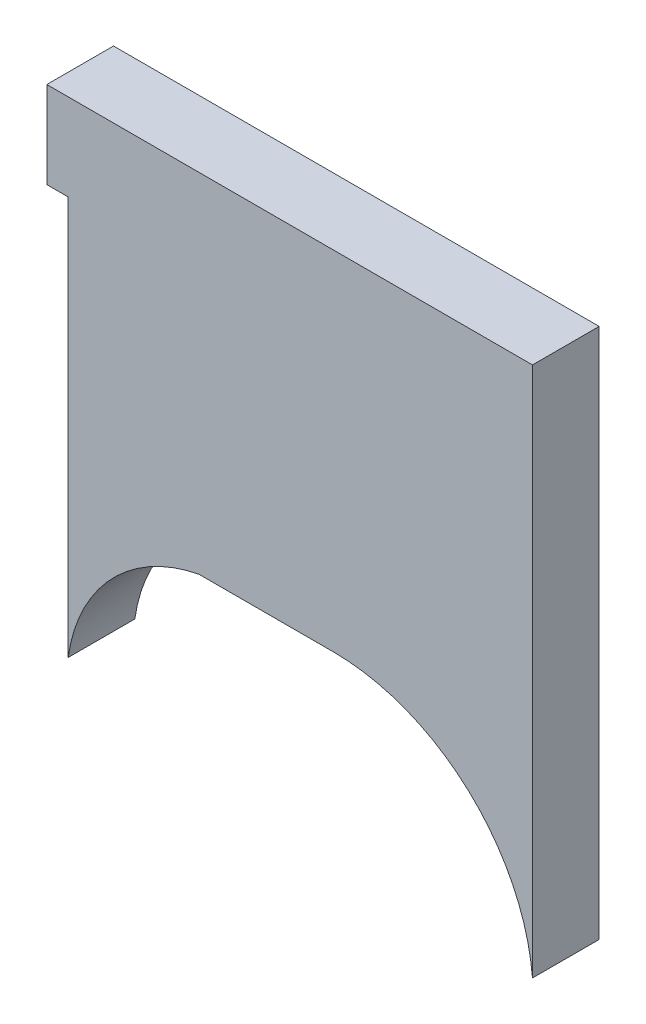
from build123d import *

# Parameters (mm, degrees)
BOSS_EXTRUDE1_DEPTH = 3.175


with BuildPart() as part:
    # Sketch2 → Boss-Extrude1 (new body)
    with BuildSketch(Plane.XY):
        with BuildLine():
            Line((-53.289355313, 44.697336176), (-53.289355313, 58.726871404))
            Line((-53.289355313, 58.726871404), (-54.556581117, 58.726871404))
            Line((-54.556581117, 58.726871404), (-76.407989953, 58.726871404))
            Line((-76.407989953, 58.726871404), (-76.407989953, 54.599371404))
            Line((-76.407989953, 54.599371404), (-75.392935047, 54.599371404))
            Line((-75.392935047, 54.599371404), (-75.392935047, 35.612017339))
            ThreePointArc((-75.392935047, 35.612017339), (-73.32810933, 39.884672035), (-69.162286351, 42.157336176))
            Line((-69.162286351, 42.157336176), (-66.247989953, 42.157336176))
            Line((-66.247989953, 42.157336176), (-62.779018686, 42.157336176))
            ThreePointArc((-62.779018686, 42.157336176), (-56.340154353, 39.651356842), (-53.289355313, 33.45203982))
            Line((-53.289355313, 33.45203982), (-53.289355313, 42.157336176))
            Line((-53.289355313, 42.157336176), (-53.289355313, 44.697336176))
        make_face()
    extrude(amount=BOSS_EXTRUDE1_DEPTH)


solid = part.part
